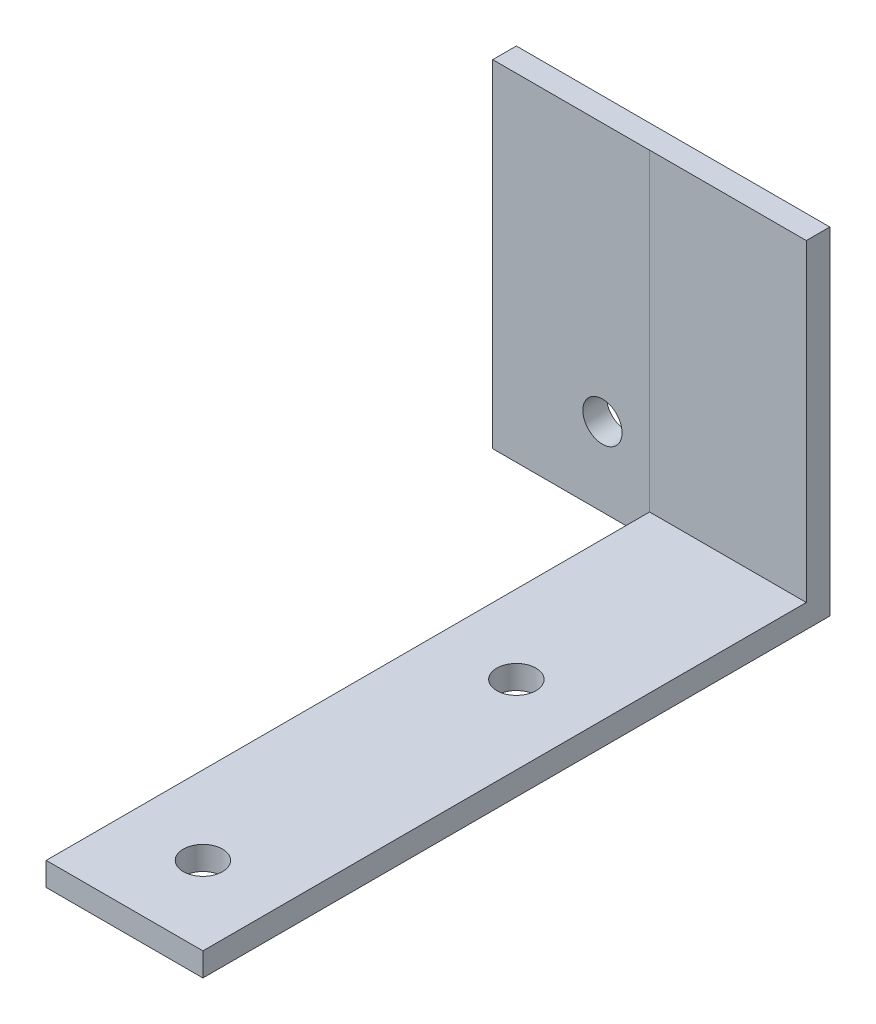
from build123d import *

# Parameters (mm, degrees)
SKETCH1_W           = 20
SKETCH1_H           = 80
SKETCH1_R           = 2.5
BOSS_EXTRUDE1_DEPTH = 3
SKETCH2_W           = 20
SKETCH2_H           = 3
BOSS_EXTRUDE2_DEPTH = 40
SKETCH4_W           = 3.015323491
SKETCH4_H           = 43
BOSS_EXTRUDE4_DEPTH = 20
SKETCH7_R           = 2.5
CUT_EXTRUDE2_DEPTH  = 20


with BuildPart() as part:
    # Sketch1 → Boss-Extrude1 (new body)
    with BuildSketch(Plane(origin=(0, 0, 0), x_dir=(1, 0, 0), z_dir=(0, 1, 0))):
        Rectangle(SKETCH1_W, SKETCH1_H)
        with Locations((0, -30)):
            Circle(SKETCH1_R, mode=Mode.SUBTRACT)
        with Locations((0, 10)):
            Circle(SKETCH1_R, mode=Mode.SUBTRACT)
    extrude(amount=BOSS_EXTRUDE1_DEPTH)

    # Sketch2 → Boss-Extrude2 (add)
    with BuildSketch(Plane(origin=(0, 3, 0), x_dir=(1, 0, 0), z_dir=(0, 1, 0))):
        with Locations((0, 38.5)):
            Rectangle(SKETCH2_W, SKETCH2_H)
    extrude(amount=BOSS_EXTRUDE2_DEPTH)

    # Sketch4 → Boss-Extrude4 (add)
    with BuildSketch(Plane.ZY.offset(10)):
        with Locations((-38.492338254, 21.5)):
            Rectangle(SKETCH4_W, SKETCH4_H)
    extrude(amount=BOSS_EXTRUDE4_DEPTH)

    # Sketch7 → Cut-Extrude2 (cut)
    with BuildSketch(Plane(origin=(0, 0, -40), x_dir=(-1, 0, 0), z_dir=(0, 0, -1))):
        with Locations((16, 10)):
            Circle(SKETCH7_R)
    extrude(amount=-CUT_EXTRUDE2_DEPTH, mode=Mode.SUBTRACT)


solid = part.part
